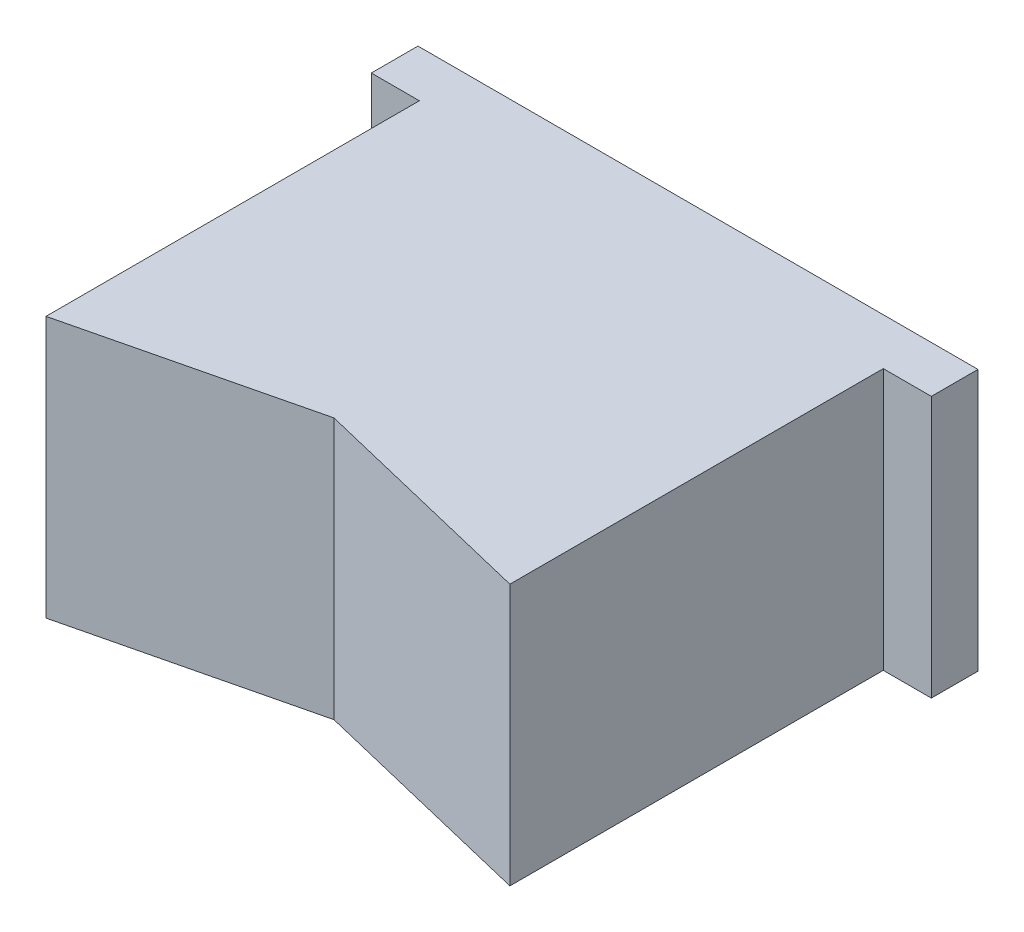
from build123d import *

# Parameters (mm, degrees)
CROQUIS1_W              = 30
CROQUIS1_H              = 14
SALIENTE_EXTRUIR1_DEPTH = 2.5
CROQUIS2_W              = 24.85
CROQUIS2_H              = 14
SALIENTE_EXTRUIR2_DEPTH = 20
CORTAR_EXTRUIR1_DEPTH   = 20


with BuildPart() as part:
    # Croquis1 → Saliente-Extruir1 (new body)
    with BuildSketch(Plane.XY):
        Rectangle(CROQUIS1_W, CROQUIS1_H)
    extrude(amount=SALIENTE_EXTRUIR1_DEPTH)

    # Croquis2 → Saliente-Extruir2 (add)
    with BuildSketch(Plane.XY.offset(2.5)):
        Rectangle(CROQUIS2_W, CROQUIS2_H)
    extrude(amount=SALIENTE_EXTRUIR2_DEPTH)

    # Croquis4 → Cortar-Extruir1 (cut)
    with BuildSketch(Plane(origin=(0, 7, 0), x_dir=(1, 0, 0), z_dir=(0, 1, 0))):
        Polygon((-12.425, -22.5), (0, -19.5), (12.425, -22.5), align=None)
    extrude(amount=-CORTAR_EXTRUIR1_DEPTH, mode=Mode.SUBTRACT)


solid = part.part
